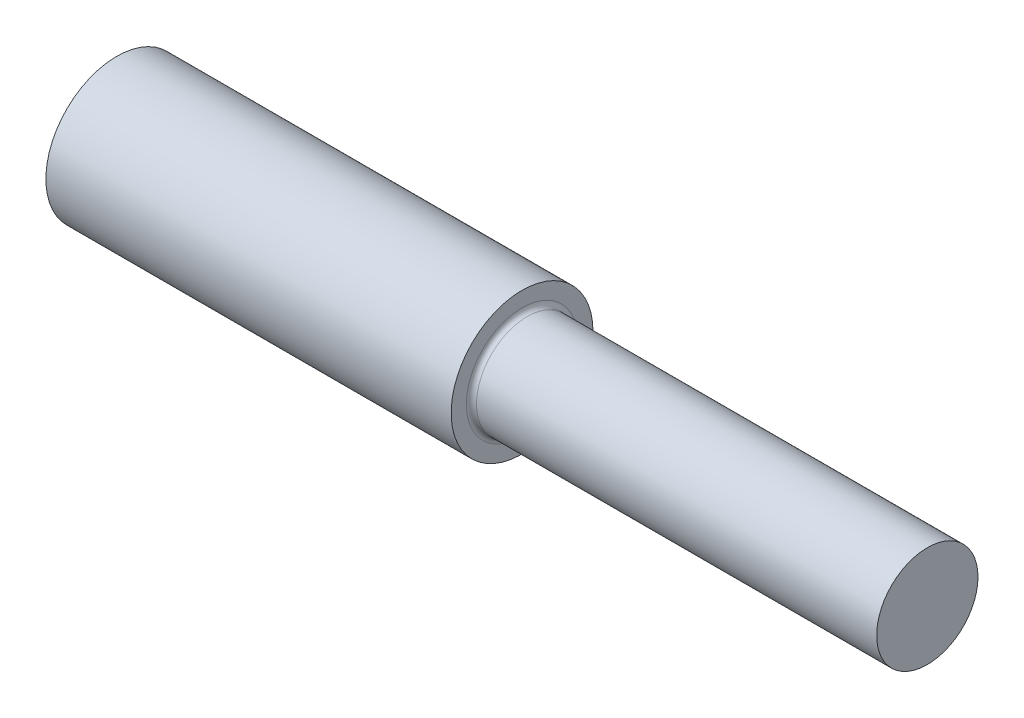
from build123d import *

# Parameters (mm, degrees)
SKETCH1_R               = 17.78
LARGE_DIA_SEGMENT_DEPTH = 101.6
SKETCH2_R               = 12.7
SMALL_DIA_SEGMENT_DEPTH = 101.6
FILLET_0_05_IN_R        = 1.27


with BuildPart() as part:
    # Sketch1 → Large Dia Segment (new body)
    with BuildSketch(Plane(origin=(0, 0, 0), x_dir=(0, 0, -1), z_dir=(1, 0, 0))):
        Circle(SKETCH1_R)
    extrude(amount=LARGE_DIA_SEGMENT_DEPTH)

    # Sketch2 → Small Dia Segment (add)
    with BuildSketch(Plane(origin=(101.6, 0, 0), x_dir=(0, 0, -1), z_dir=(1, 0, 0))):
        Circle(SKETCH2_R)
    extrude(amount=SMALL_DIA_SEGMENT_DEPTH)

    # Fillet 0.05 in
    fillet_0_05_in_edges = [part.edges().sort_by_distance(p)[0] for p in [
        (101.6, 0, 12.7),
    ]]
    fillet(fillet_0_05_in_edges, radius=FILLET_0_05_IN_R)


solid = part.part
